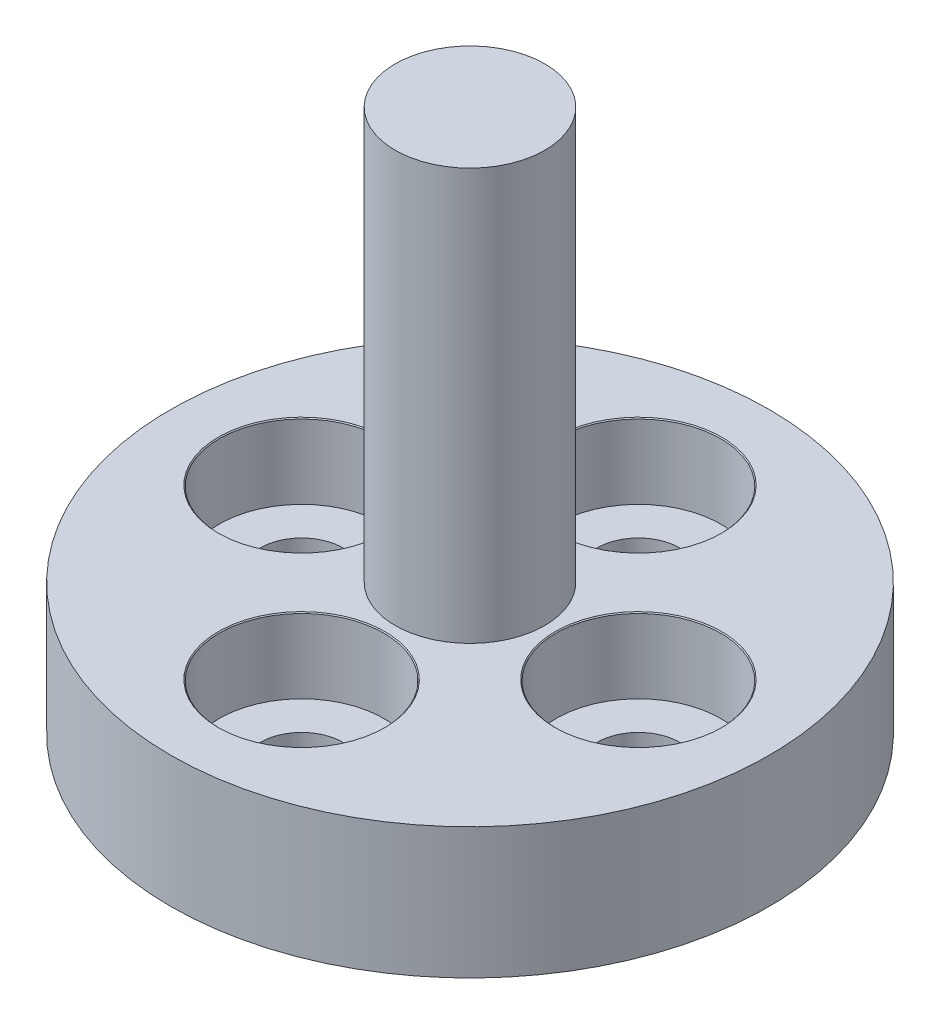
from build123d import *

# Parameters (mm, degrees)
CBORE_FOR_M2_SHCS1_AT_2_COUNT = 2
CBORE_FOR_M2_SHCS1_AT_2_PITCH = 6.363961031
CBORE_FOR_M2_SHCS1_AT_3_COUNT = 2
CBORE_FOR_M2_SHCS1_AT_3_PITCH = 9
CBORE_FOR_M2_SHCS1_AT_4_COUNT = 2
CBORE_FOR_M2_SHCS1_AT_4_PITCH = 6.363961031


with BuildPart() as part:
    # Sketch1 → Revolve1 (revolve)
    with BuildSketch(Plane.XY):
        Polygon((0, 0), (0, 14.5), (2, 14.5), (2, 3.5), (8, 3.5), (8, 0), align=None)
    revolve(axis=Axis((0, 0, 0), (0, 1, 0)))

    # Sketch5 → CBORE for M2 SHCS1 (revolve, cut)
    with BuildSketch(Plane(origin=(0, 3.5, -4.5), x_dir=(0, 0, 1), z_dir=(1, 0, 0))):
        Polygon((0, 0), (0, 3.5), (1.1, 3.5), (1.1, 2), (2.2, 2), (2.2, 0.025), (2.225, 0), align=None)
    cbore_for_m2_shcs1 = revolve(axis=Axis((0, 9.85, -4.5), (0, -1, 0)), mode=Mode.SUBTRACT)

    # CBORE for M2 SHCS1 at 2: CBORE for M2 SHCS1 ×2
    with Locations(*[Vector(0.707106781, 0, 0.707106781) * (i * CBORE_FOR_M2_SHCS1_AT_2_PITCH) for i in range(1, CBORE_FOR_M2_SHCS1_AT_2_COUNT)]):
        add(cbore_for_m2_shcs1, mode=Mode.SUBTRACT)

    # CBORE for M2 SHCS1 at 3: CBORE for M2 SHCS1 ×2
    with Locations(*[(0, 0, i * CBORE_FOR_M2_SHCS1_AT_3_PITCH) for i in range(1, CBORE_FOR_M2_SHCS1_AT_3_COUNT)]):
        add(cbore_for_m2_shcs1, mode=Mode.SUBTRACT)

    # CBORE for M2 SHCS1 at 4: CBORE for M2 SHCS1 ×2
    with Locations(*[Vector(-0.707106781, 0, 0.707106781) * (i * CBORE_FOR_M2_SHCS1_AT_4_PITCH) for i in range(1, CBORE_FOR_M2_SHCS1_AT_4_COUNT)]):
        add(cbore_for_m2_shcs1, mode=Mode.SUBTRACT)


solid = part.part
